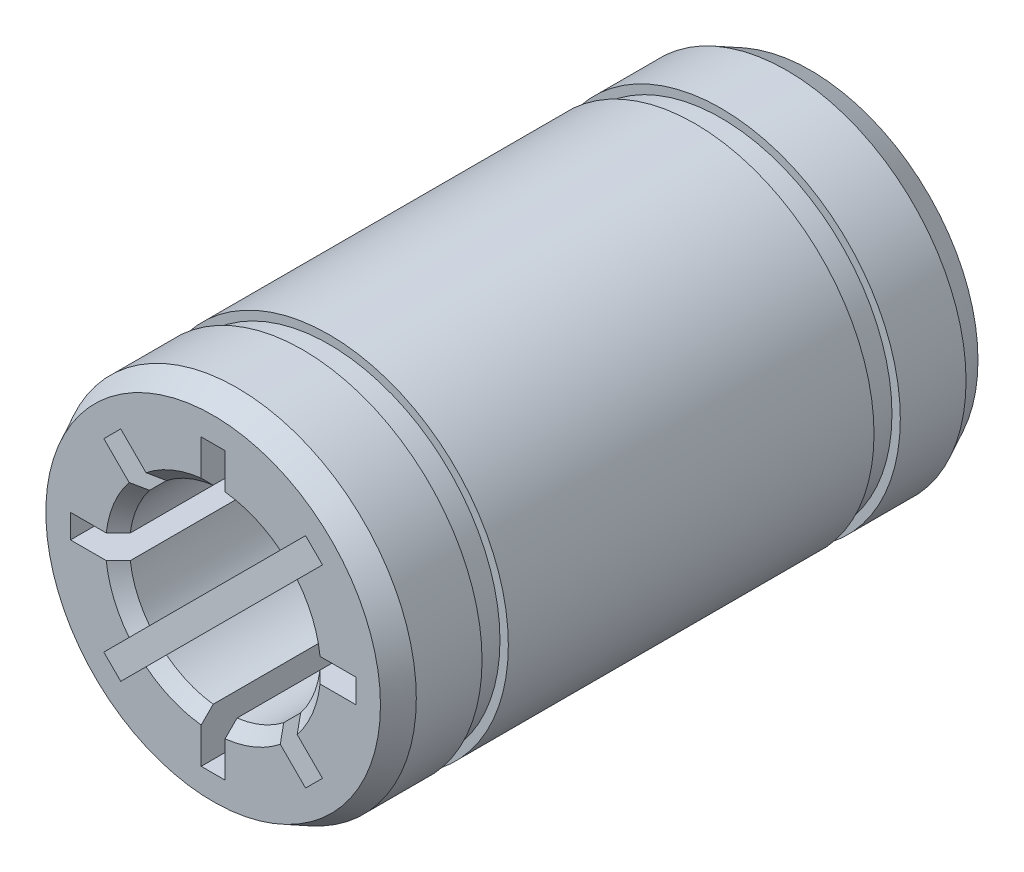
from build123d import *

# Parameters (mm, degrees)
ESQUISSE1_R        = 7.5
BOSS_EXTRU_1_DEPTH = 12.5
ESQUISSE2_W        = 1.1
ESQUISSE2_H        = 0.35
CHANFREIN1_SIZE    = 1
CHANFREIN1_SIZE2   = 0.5
CHANFREIN2_SIZE    = 0.5
CHANFREIN2_SIZE2   = 1
CHANFREIN3_SIZE    = 0.5


with BuildPart() as part:
    # Esquisse1 → Boss.-Extru.1 (new body, symmetric)
    with BuildSketch(Plane.XY):
        Circle(ESQUISSE1_R)
        with BuildLine():
            Line((3.866903212, 4.574009993), (2.452689649, 3.159796431))
            ThreePointArc((2.452689649, 3.159796431), (1.530733729, 3.69551813), (0.5, 3.968626967))
            Line((0.5, 3.968626967), (0.5, 5.968626967))
            Line((0.5, 5.968626967), (-0.5, 5.968626967))
            Line((-0.5, 5.968626967), (-0.5, 3.968626967))
            ThreePointArc((-0.5, 3.968626967), (-1.530733729, 3.69551813), (-2.452689649, 3.159796431))
            Line((-2.452689649, 3.159796431), (-3.866903212, 4.574009993))
            Line((-3.866903212, 4.574009993), (-4.574009993, 3.866903212))
            Line((-4.574009993, 3.866903212), (-3.159796431, 2.452689649))
            ThreePointArc((-3.159796431, 2.452689649), (-3.69551813, 1.530733729), (-3.968626967, 0.5))
            Line((-3.968626967, 0.5), (-5.968626967, 0.5))
            Line((-5.968626967, 0.5), (-5.968626967, -0.5))
            Line((-5.968626967, -0.5), (-3.968626967, -0.5))
            ThreePointArc((-3.968626967, -0.5), (-3.69551813, -1.530733729), (-3.159796431, -2.452689649))
            Line((-3.159796431, -2.452689649), (-4.574009993, -3.866903212))
            Line((-4.574009993, -3.866903212), (-3.866903212, -4.574009993))
            Line((-3.866903212, -4.574009993), (-2.452689649, -3.159796431))
            ThreePointArc((-2.452689649, -3.159796431), (-1.530733729, -3.69551813), (-0.5, -3.968626967))
            Line((-0.5, -3.968626967), (-0.5, -5.968626967))
            Line((-0.5, -5.968626967), (0.5, -5.968626967))
            Line((0.5, -5.968626967), (0.5, -3.968626967))
            ThreePointArc((0.5, -3.968626967), (1.530733729, -3.69551813), (2.452689649, -3.159796431))
            Line((2.452689649, -3.159796431), (3.866903212, -4.574009993))
            Line((3.866903212, -4.574009993), (4.574009993, -3.866903212))
            Line((4.574009993, -3.866903212), (3.159796431, -2.452689649))
            ThreePointArc((3.159796431, -2.452689649), (3.69551813, -1.530733729), (3.968626967, -0.5))
            Line((3.968626967, -0.5), (5.968626967, -0.5))
            Line((5.968626967, -0.5), (5.968626967, 0.5))
            Line((5.968626967, 0.5), (3.968626967, 0.5))
            ThreePointArc((3.968626967, 0.5), (3.69551813, 1.530733729), (3.159796431, 2.452689649))
            Line((3.159796431, 2.452689649), (4.574009993, 3.866903212))
            Line((4.574009993, 3.866903212), (3.866903212, 4.574009993))
        make_face(mode=Mode.SUBTRACT)
    extrude(amount=BOSS_EXTRU_1_DEPTH, both=True)

    # Esquisse2 → Enlèvement de matière-Révolution1 (revolve, cut)
    with BuildSketch(Plane(origin=(0, 0, 0), x_dir=(0, 0, -1), z_dir=(1, 0, 0))):
        with Locations((-8.2, 7.325)):
            Rectangle(ESQUISSE2_W, ESQUISSE2_H)
        with Locations((8.2, 7.325)):
            Rectangle(ESQUISSE2_W, ESQUISSE2_H)
    revolve(axis=Axis((0, 0, 12.5), (0, 0, -1)), mode=Mode.SUBTRACT)

    # Chanfrein1
    chanfrein1_edges = [part.edges().sort_by_distance(p)[0] for p in [
        (-7.5, 0, 12.5),
    ]]
    chanfrein1_side = [part.faces().sort_by_distance(p)[0] for p in [
        (-7.5, 0, 10.625),
    ]]
    chamfer(chanfrein1_edges, length=CHANFREIN1_SIZE, length2=CHANFREIN1_SIZE2, reference=chanfrein1_side[0])

    # Chanfrein2
    chanfrein2_edges = [part.edges().sort_by_distance(p)[0] for p in [
        (-7.5, 0, -12.5),
    ]]
    chanfrein2_side = [part.faces().sort_by_distance(p)[0] for p in [
        (-7.287867966, 0, -12.5),
    ]]
    chamfer(chanfrein2_edges, length=CHANFREIN2_SIZE, length2=CHANFREIN2_SIZE2, reference=chanfrein2_side[0])

    # Chanfrein3
    chanfrein3_edges = [part.edges().sort_by_distance(p)[0] for p in [
        (-1.530733729, 3.69551813, -12.5),
        (-3.69551813, 1.530733729, -12.5),
        (-3.69551813, -1.530733729, -12.5),
        (-1.530733729, -3.69551813, -12.5),
        (1.530733729, -3.69551813, -12.5),
        (3.69551813, -1.530733729, -12.5),
        (3.69551813, 1.530733729, -12.5),
        (1.530733729, 3.69551813, -12.5),
        (-1.530733729, 3.69551813, 12.5),
        (-3.69551813, 1.530733729, 12.5),
        (-3.69551813, -1.530733729, 12.5),
        (-1.530733729, -3.69551813, 12.5),
        (1.530733729, -3.69551813, 12.5),
        (3.69551813, -1.530733729, 12.5),
        (3.69551813, 1.530733729, 12.5),
        (1.530733729, 3.69551813, 12.5),
    ]]
    chamfer(chanfrein3_edges, length=CHANFREIN3_SIZE)


solid = part.part
